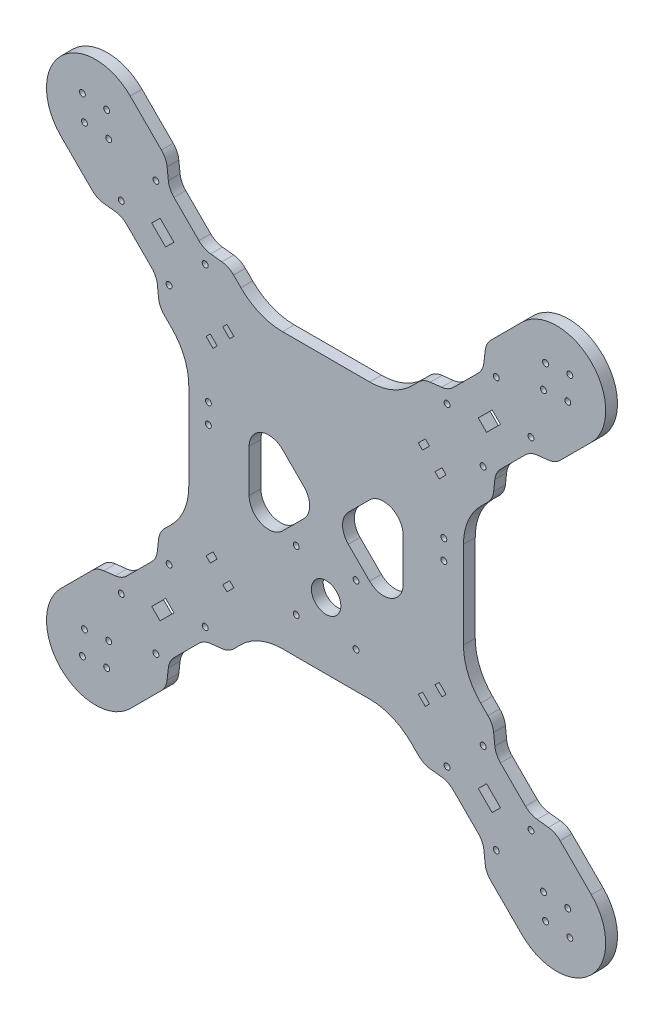
from build123d import *

# Parameters (mm, degrees)
BOSS_EXTRUDE1_DEPTH      = 6
FILLET1_R                = 30
SKETCH8_R                = 1.5
CUT_EXTRUDE1_DEPTH       = 202.614731605
SKETCH9_R                = 1.5
CUT_EXTRUDE2_DEPTH       = 202.614731605
MIRROR2_COPY_1_SKETCH_R  = 1.5
MIRROR2_COPY_1_DEPTH     = 202.614731605
MIRROR2_COPY_2_SKETCH_R  = 1.5
MIRROR2_COPY_2_DEPTH     = 202.614731605
MIRROR2_COPY_3_SKETCH_R  = 1.5
MIRROR2_COPY_3_DEPTH     = 202.614731605
MIRROR2_COPY_4_SKETCH_R  = 1.5
MIRROR2_COPY_4_DEPTH     = 202.614731605
CUT_EXTRUDE3_DEPTH       = 202.614731605
CUT_EXTRUDE3_DEPTH_BACK  = 202.614731605
SKETCH10_R               = 1.5
SKETCH10_R_2             = 1.499999999
SKETCH10_R_3             = 7.5
FILLET2_R                = 10
CUT_EXTRUDE4_DEPTH       = 202.614731605
CIRPATTERN2_COUNT        = 4
CIRPATTERN2_COPY_1_DEPTH = 202.614731605
CIRPATTERN2_COPY_2_DEPTH = 202.614731605
CIRPATTERN2_COPY_3_DEPTH = 202.614731605
FILLET3_R                = 10


with BuildPart() as part:
    # Sketch4 → Boss-Extrude1 (new body)
    with BuildSketch(Plane.XY):
        with BuildLine():
            Line((-70, -34.644660941), (-70, 34.644660941))
            Line((-70, 34.644660941), (-135.17766953, 99.82233047))
            ThreePointArc((-135.17766953, 99.82233047), (-135.17766953, 135.17766953), (-99.82233047, 135.17766953))
            Line((-99.82233047, 135.17766953), (-34.644660941, 70))
            Line((-34.644660941, 70), (34.644660941, 70))
            Line((34.644660941, 70), (99.82233047, 135.17766953))
            ThreePointArc((99.82233047, 135.17766953), (135.17766953, 135.17766953), (135.17766953, 99.82233047))
            Line((135.17766953, 99.82233047), (70, 34.644660941))
            Line((70, 34.644660941), (70, -34.644660941))
            Line((70, -34.644660941), (135.17766953, -99.82233047))
            ThreePointArc((135.17766953, -99.82233047), (135.17766953, -135.17766953), (99.82233047, -135.17766953))
            Line((99.82233047, -135.17766953), (34.644660941, -70))
            Line((34.644660941, -70), (-34.644660941, -70))
            Line((-34.644660941, -70), (-99.82233047, -135.17766953))
            ThreePointArc((-99.82233047, -135.17766953), (-135.17766953, -135.17766953), (-135.17766953, -99.82233047))
            Line((-135.17766953, -99.82233047), (-70, -34.644660941))
        make_face()
    extrude(amount=BOSS_EXTRUDE1_DEPTH)

    # Fillet1
    fillet1_edges = [part.edges().sort_by_distance(p)[0] for p in [
        (34.644660941, -70, 3),
        (70, -34.644660941, 3),
        (70, 34.644660941, 3),
        (34.644660941, 70, 3),
        (-34.644660941, 70, 3),
        (-70, 34.644660941, 3),
        (-70, -34.644660941, 3),
        (-34.644660941, -70, 3),
    ]]
    fillet(fillet1_edges, radius=FILLET1_R)

    # Sketch8 → Cut-Extrude1 (cut, symmetric)
    with BuildSketch(Plane.XY.offset(6)):
        with Locations((-104.418524548, 86.740855018)):
            Circle(SKETCH8_R)
        with Locations((-80.023340597, 61.638564286)):
            Circle(SKETCH8_R)
        with Locations((-86.740855018, 104.418524548)):
            Circle(SKETCH8_R)
        with Locations((-61.638564286, 80.023340597)):
            Circle(SKETCH8_R)
        Polygon((-88.862175362, 84.619534675), (-84.619534675, 88.862175362), (-77.548466863, 81.79110755), (-81.79110755, 77.548466863), align=None)
    cut_extrude1 = extrude(amount=CUT_EXTRUDE1_DEPTH, both=True, mode=Mode.SUBTRACT)

    # Sketch9 → Cut-Extrude2 (cut, symmetric)
    with BuildSketch(Plane.XY.offset(6)):
        with Locations((-124.217514421, 124.217514421)):
            Circle(SKETCH9_R)
        with Locations((-110.782485579, 110.782485579)):
            Circle(SKETCH9_R)
        with Locations((-123.156854249, 111.843145751)):
            Circle(SKETCH9_R)
        with Locations((-111.843145751, 123.156854249)):
            Circle(SKETCH9_R)
    cut_extrude2 = extrude(amount=CUT_EXTRUDE2_DEPTH, both=True, mode=Mode.SUBTRACT)

    # Mirror1: Cut-Extrude1, Cut-Extrude2 across plane
    add(cut_extrude1.mirror(Plane(origin=(0, 0, 0), x_dir=(0, 0, 1), z_dir=(1, 0, 0))), mode=Mode.SUBTRACT)
    add(cut_extrude2.mirror(Plane(origin=(0, 0, 0), x_dir=(0, 0, 1), z_dir=(1, 0, 0))), mode=Mode.SUBTRACT)

    # Mirror2 copy 1 sketch → Mirror2 copy 1 (cut, symmetric)
    with BuildSketch(Plane(origin=(0, 0, 6), x_dir=(-1, 0, 0), z_dir=(0, 0, 1))):
        with Locations((-104.418524548, 86.740855018)):
            Circle(MIRROR2_COPY_1_SKETCH_R)
        with Locations((-80.023340597, 61.638564286)):
            Circle(MIRROR2_COPY_1_SKETCH_R)
        with Locations((-86.740855018, 104.418524548)):
            Circle(MIRROR2_COPY_1_SKETCH_R)
        with Locations((-61.638564286, 80.023340597)):
            Circle(MIRROR2_COPY_1_SKETCH_R)
        Polygon((-88.862175362, 84.619534675), (-84.619534675, 88.862175362), (-77.548466863, 81.79110755), (-81.79110755, 77.548466863), align=None)
    extrude(amount=MIRROR2_COPY_1_DEPTH, both=True, mode=Mode.SUBTRACT)

    # Mirror2 copy 2 sketch → Mirror2 copy 2 (cut, symmetric)
    with BuildSketch(Plane(origin=(0, 0, 6), x_dir=(-1, 0, 0), z_dir=(0, 0, 1))):
        with Locations((-124.217514421, 124.217514421)):
            Circle(MIRROR2_COPY_2_SKETCH_R)
        with Locations((-110.782485579, 110.782485579)):
            Circle(MIRROR2_COPY_2_SKETCH_R)
        with Locations((-123.156854249, 111.843145751)):
            Circle(MIRROR2_COPY_2_SKETCH_R)
        with Locations((-111.843145751, 123.156854249)):
            Circle(MIRROR2_COPY_2_SKETCH_R)
    extrude(amount=MIRROR2_COPY_2_DEPTH, both=True, mode=Mode.SUBTRACT)

    # Mirror2 copy 3 sketch → Mirror2 copy 3 (cut, symmetric)
    with BuildSketch(Plane.XY.offset(6)):
        with Locations((-104.418524548, -86.740855018)):
            Circle(MIRROR2_COPY_3_SKETCH_R)
        with Locations((-80.023340597, -61.638564286)):
            Circle(MIRROR2_COPY_3_SKETCH_R)
        with Locations((-86.740855018, -104.418524548)):
            Circle(MIRROR2_COPY_3_SKETCH_R)
        with Locations((-61.638564286, -80.023340597)):
            Circle(MIRROR2_COPY_3_SKETCH_R)
        Polygon((-88.862175362, -84.619534675), (-84.619534675, -88.862175362), (-77.548466863, -81.79110755), (-81.79110755, -77.548466863), align=None)
    extrude(amount=MIRROR2_COPY_3_DEPTH, both=True, mode=Mode.SUBTRACT)

    # Mirror2 copy 4 sketch → Mirror2 copy 4 (cut, symmetric)
    with BuildSketch(Plane.XY.offset(6)):
        with Locations((-124.217514421, -124.217514421)):
            Circle(MIRROR2_COPY_4_SKETCH_R)
        with Locations((-110.782485579, -110.782485579)):
            Circle(MIRROR2_COPY_4_SKETCH_R)
        with Locations((-123.156854249, -111.843145751)):
            Circle(MIRROR2_COPY_4_SKETCH_R)
        with Locations((-111.843145751, -123.156854249)):
            Circle(MIRROR2_COPY_4_SKETCH_R)
    extrude(amount=MIRROR2_COPY_4_DEPTH, both=True, mode=Mode.SUBTRACT)

    # Sketch10 → Cut-Extrude3 (cut, two sides: drawn at the far end of the back side and taken through both)
    with BuildSketch(Plane.XY.offset(6).offset(-CUT_EXTRUDE3_DEPTH_BACK)):
        with Locations((-60, 20)):
            Circle(SKETCH10_R)
        with Locations((-60, 10)):
            Circle(SKETCH10_R)
        with Locations((60, 20)):
            Circle(SKETCH10_R)
        with Locations((60, 10)):
            Circle(SKETCH10_R)
        with Locations((-15.249999999, -21)):
            Circle(SKETCH10_R_2)
        with Locations((15.249999999, -21)):
            Circle(SKETCH10_R)
        with Locations((-15.249999999, -51.5)):
            Circle(SKETCH10_R_2)
        with Locations((15.249999999, -51.5)):
            Circle(SKETCH10_R)
        with Locations((0, -36.249999999)):
            Circle(SKETCH10_R_3)
        Polygon((-49.142135624, -53.384776311), (-47.02081528, -55.506096654), (-50.556349186, -59.04163056), (-52.67766953, -56.920310217), align=None)
        Polygon((-4.242640687, 0), (-39.242640687, 35), (-39.242640687, -35), align=None)
        Polygon((39.242640687, 35), (39.242640687, -35), (4.242640687, 0), align=None)
        Polygon((-57.627416998, -44.899494937), (-55.506096654, -47.02081528), (-59.04163056, -50.556349186), (-61.162950904, -48.435028843), align=None)
        Polygon((-61.162950904, 48.435028843), (-59.04163056, 50.556349186), (-55.506096654, 47.02081528), (-57.627416998, 44.899494937), align=None)
        Polygon((57.627416998, 44.899494937), (55.506096654, 47.02081528), (59.04163056, 50.556349186), (61.162950904, 48.435028843), align=None)
        Polygon((61.162950904, -48.435028843), (57.627416998, -44.899494937), (55.506096654, -47.02081528), (59.04163056, -50.556349186), align=None)
        Polygon((-52.67766953, 56.920310217), (-50.556349186, 59.04163056), (-47.02081528, 55.506096654), (-49.142135624, 53.384776311), align=None)
        Polygon((52.67766953, -56.920310217), (49.142135624, -53.384776311), (47.02081528, -55.506096654), (50.556349186, -59.04163056), align=None)
        Polygon((49.142135624, 53.384776311), (47.02081528, 55.506096654), (50.556349186, 59.04163056), (52.67766953, 56.920310217), align=None)
    extrude(amount=CUT_EXTRUDE3_DEPTH + CUT_EXTRUDE3_DEPTH_BACK, mode=Mode.SUBTRACT)

    # Fillet2
    fillet2_edges = [part.edges().sort_by_distance(p)[0] for p in [
        (4.242640687, 0, 3),
        (39.242640687, -35, 3),
        (39.242640687, 35, 3),
        (-39.242640687, -35, 3),
        (-39.242640687, 35, 3),
        (-4.242640687, 0, 3),
    ]]
    fillet(fillet2_edges, radius=FILLET2_R)

    # Sketch11 → Cut-Extrude4 (cut, symmetric)
    with BuildSketch(Plane.XY.offset(6)):
        Polygon((-80.023340597, 104.064971157), (-62.345671067, 86.387301628), (-49.617749006, 84.973088065), (-81.437554159, 116.792893219), align=None)
    cut_extrude4 = extrude(amount=CUT_EXTRUDE4_DEPTH, both=True, mode=Mode.SUBTRACT)

    # Mirror4: Cut-Extrude4 across plane
    add(cut_extrude4.mirror(Plane(origin=(0, 0, 0), x_dir=(0, 0, 1), z_dir=(0.7071067811865474, 0.7071067811865477, 0))), mode=Mode.SUBTRACT)

    # CirPattern2: Cut-Extrude4 ×4 about axis
    cirpattern2_axis = Axis((0, 0, 0), (0, 0, 1))
    for i in range(1, CIRPATTERN2_COUNT):
        add(cut_extrude4.rotate(cirpattern2_axis, i * 360 / CIRPATTERN2_COUNT), mode=Mode.SUBTRACT)

    # CirPattern2 copy 1 sketch → CirPattern2 copy 1 (cut, symmetric)
    with BuildSketch(Plane.XY.offset(6)):
        Polygon((-80.023340597, -104.064971157), (-62.345671067, -86.387301628), (-49.617749006, -84.973088065), (-81.437554159, -116.792893219), align=None)
    extrude(amount=CIRPATTERN2_COPY_1_DEPTH, both=True, mode=Mode.SUBTRACT)

    # CirPattern2 copy 2 sketch → CirPattern2 copy 2 (cut, symmetric)
    with BuildSketch(Plane(origin=(0, 0, 6), x_dir=(0, 1, 0), z_dir=(0, 0, 1))):
        Polygon((-80.023340597, -104.064971157), (-62.345671067, -86.387301628), (-49.617749006, -84.973088065), (-81.437554159, -116.792893219), align=None)
    extrude(amount=CIRPATTERN2_COPY_2_DEPTH, both=True, mode=Mode.SUBTRACT)

    # CirPattern2 copy 3 sketch → CirPattern2 copy 3 (cut, symmetric)
    with BuildSketch(Plane(origin=(0, 0, 6), x_dir=(-1, 0, 0), z_dir=(0, 0, 1))):
        Polygon((-80.023340597, -104.064971157), (-62.345671067, -86.387301628), (-49.617749006, -84.973088065), (-81.437554159, -116.792893219), align=None)
    extrude(amount=CIRPATTERN2_COPY_3_DEPTH, both=True, mode=Mode.SUBTRACT)

    # Fillet3
    fillet3_edges = [part.edges().sort_by_distance(p)[0] for p in [
        (-49.617749006, 84.973088065, 3),
        (-62.345671067, 86.387301628, 3),
        (-80.023340597, 104.064971157, 3),
        (-81.437554159, 116.792893219, 3),
        (116.792893219, 81.437554159, 3),
        (104.064971157, 80.023340597, 3),
        (86.387301628, 62.345671067, 3),
        (84.973088065, 49.617749006, 3),
        (80.023340597, 104.064971157, 3),
        (81.437554159, 116.792893219, 3),
        (62.345671067, 86.387301628, 3),
        (49.617749006, 84.973088065, 3),
        (116.792893219, -81.437554159, 3),
        (104.064971157, -80.023340597, 3),
        (86.387301628, -62.345671067, 3),
        (84.973088065, -49.617749006, 3),
        (81.437554159, -116.792893219, 3),
        (80.023340597, -104.064971157, 3),
        (62.345671067, -86.387301628, 3),
        (49.617749006, -84.973088065, 3),
        (-49.617749006, -84.973088065, 3),
        (-62.345671067, -86.387301628, 3),
        (-80.023340597, -104.064971157, 3),
        (-81.437554159, -116.792893219, 3),
        (-116.792893219, -81.437554159, 3),
        (-104.064971157, -80.023340597, 3),
        (-86.387301628, -62.345671067, 3),
        (-84.973088065, -49.617749006, 3),
        (-84.973088065, 49.617749006, 3),
        (-86.387301628, 62.345671067, 3),
        (-104.064971157, 80.023340597, 3),
        (-116.792893219, 81.437554159, 3),
    ]]
    fillet(fillet3_edges, radius=FILLET3_R)


solid = part.part
